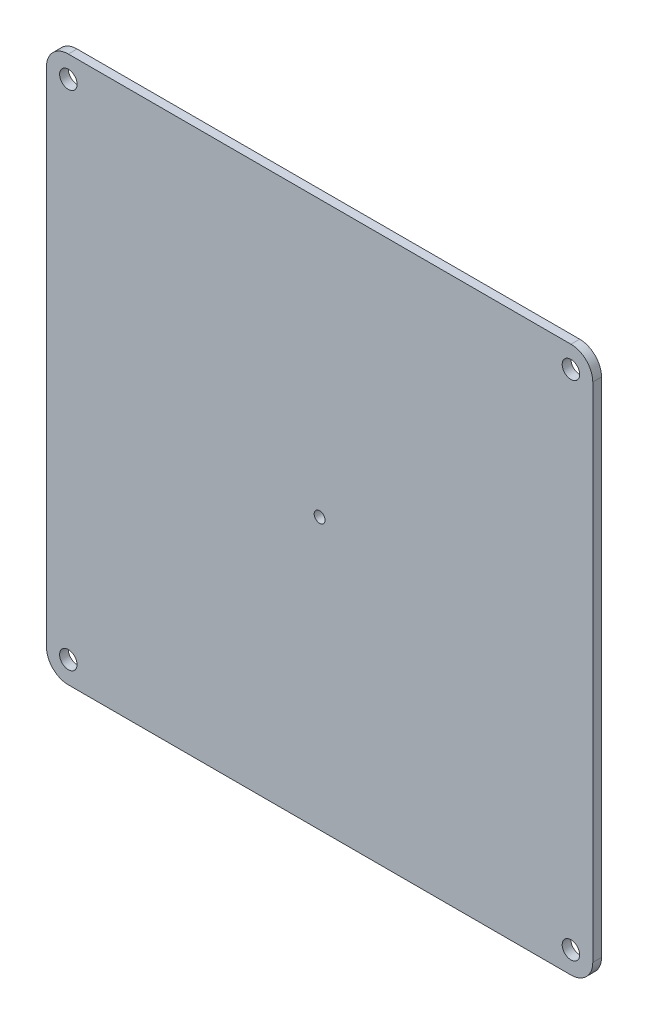
from build123d import *

# Parameters (mm, degrees)
SKETCH1_R           = 1.6
SKETCH1_R_2         = 1
BOSS_EXTRUDE1_DEPTH = 1.6


with BuildPart() as part:
    # Sketch1 → Boss-Extrude1 (new body)
    with BuildSketch(Plane.XY):
        with BuildLine():
            Line((46, -50), (-46, -50))
            ThreePointArc((-46, -50), (-48.828427125, -48.828427125), (-50, -46))
            Line((-50, -46), (-50, 46))
            ThreePointArc((-50, 46), (-48.828427125, 48.828427125), (-46, 50))
            Line((-46, 50), (46, 50))
            ThreePointArc((46, 50), (48.828427125, 48.828427125), (50, 46))
            Line((50, 46), (50, -46))
            ThreePointArc((50, -46), (48.828427125, -48.828427125), (46, -50))
        make_face()
        with Locations((-46, 46)):
            Circle(SKETCH1_R, mode=Mode.SUBTRACT)
        with Locations((0, -0.4)):
            Circle(SKETCH1_R_2, mode=Mode.SUBTRACT)
        with Locations((46, 46)):
            Circle(SKETCH1_R, mode=Mode.SUBTRACT)
        with Locations((46, -46)):
            Circle(SKETCH1_R, mode=Mode.SUBTRACT)
        with Locations((-46, -46)):
            Circle(SKETCH1_R, mode=Mode.SUBTRACT)
    extrude(amount=BOSS_EXTRUDE1_DEPTH)


solid = part.part
